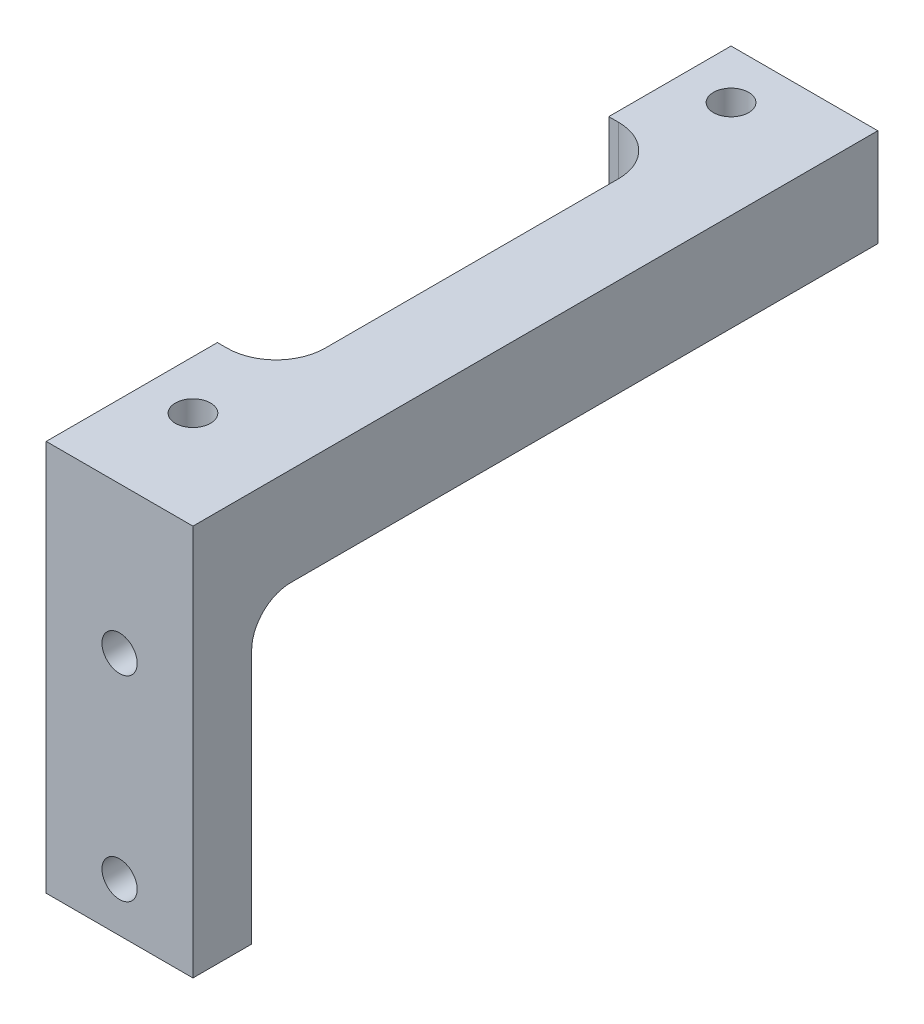
from build123d import *

# Parameters (mm, degrees)
SKETCH2_W           = 47.625
SKETCH2_H           = 25.4
BOSS_EXTRUDE1_DEPTH = 44.45
SKETCH3_W           = 28.575
SKETCH3_H           = 44.45
CUT_EXTRUDE1_DEPTH  = 26.4
SKETCH4_W           = 40.64
SKETCH4_H           = 19.05
CUT_EXTRUDE2_DEPTH  = 48.625
FILLET1_R           = 2.54
FILLET2_R           = 2.54
SKETCH5_R           = 1.143
CUT_EXTRUDE3_DEPTH  = 45.45
SKETCH6_R           = 1.143
CUT_EXTRUDE4_DEPTH  = 45.45
SKETCH7_R           = 1.143
CUT_EXTRUDE5_DEPTH  = 10.16
SKETCH8_W           = 36.195
SKETCH8_H           = 25.4
CUT_EXTRUDE6_DEPTH  = 26.4
FILLET3_R           = 3.175
FILLET4_R           = 3.175
SKETCH9_W           = 63.744217065
SKETCH9_H           = 41.287723533
CUT_EXTRUDE7_DEPTH  = 38.1


with BuildPart() as part:
    # Sketch2 → Boss-Extrude1 (new body)
    with BuildSketch(Plane.XY):
        Rectangle(SKETCH2_W, SKETCH2_H)
    extrude(amount=BOSS_EXTRUDE1_DEPTH)

    # Sketch3 → Cut-Extrude1 (cut, through all)
    with BuildSketch(Plane(origin=(0, 12.7, 0), x_dir=(1, 0, 0), z_dir=(0, 1, 0))):
        with Locations((0, -22.225)):
            Rectangle(SKETCH3_W, SKETCH3_H)
    extrude(amount=-CUT_EXTRUDE1_DEPTH, mode=Mode.SUBTRACT)

    # Sketch4 → Cut-Extrude2 (cut, through all)
    with BuildSketch(Plane.ZY.offset(23.8125)):
        with Locations((20.32, -3.175)):
            Rectangle(SKETCH4_W, SKETCH4_H)
    extrude(amount=-CUT_EXTRUDE2_DEPTH, mode=Mode.SUBTRACT)

    # Fillet1
    fillet1_edges = [part.edges().sort_by_distance(p)[0] for p in [
        (19.05, 6.35, 40.64),
    ]]
    fillet(fillet1_edges, radius=FILLET1_R)

    # Fillet2
    fillet2_edges = [part.edges().sort_by_distance(p)[0] for p in [
        (-19.05, 6.35, 40.64),
    ]]
    fillet(fillet2_edges, radius=FILLET2_R)

    # Sketch5 → Cut-Extrude3 (cut, through all)
    with BuildSketch(Plane.XY.offset(44.45)):
        with Locations((-19.05, -9.525)):
            Circle(SKETCH5_R)
        with Locations((-19.05, 3.175)):
            Circle(SKETCH5_R)
    extrude(amount=-CUT_EXTRUDE3_DEPTH, mode=Mode.SUBTRACT)

    # Sketch6 → Cut-Extrude4 (cut, through all)
    with BuildSketch(Plane.XY.offset(44.45)):
        with Locations((19.05, -9.525)):
            Circle(SKETCH6_R)
        with Locations((19.05, 3.175)):
            Circle(SKETCH6_R)
    extrude(amount=-CUT_EXTRUDE4_DEPTH, mode=Mode.SUBTRACT)

    # Sketch7 → Cut-Extrude5 (cut)
    with BuildSketch(Plane(origin=(0, 12.7, 0), x_dir=(1, 0, 0), z_dir=(0, 1, 0))):
        with Locations((-17.4625, -38.1)):
            Circle(SKETCH7_R)
        with Locations((17.4625, -38.1)):
            Circle(SKETCH7_R)
        with Locations((-17.4625, -3.175)):
            Circle(SKETCH7_R)
        with Locations((17.4625, -3.175)):
            Circle(SKETCH7_R)
    extrude(amount=-CUT_EXTRUDE5_DEPTH, mode=Mode.SUBTRACT)

    # Sketch8 → Cut-Extrude6 (cut, through all)
    with BuildSketch(Plane(origin=(0, 12.7, 0), x_dir=(1, 0, 0), z_dir=(0, 1, 0))):
        with Locations((0, -20.6375)):
            Rectangle(SKETCH8_W, SKETCH8_H)
    extrude(amount=-CUT_EXTRUDE6_DEPTH, mode=Mode.SUBTRACT)

    # Fillet3
    fillet3_edges = [part.edges().sort_by_distance(p)[0] for p in [
        (-18.0975, 9.525, 33.3375),
        (-18.0975, 9.525, 7.9375),
    ]]
    fillet(fillet3_edges, radius=FILLET3_R)

    # Fillet4
    fillet4_edges = [part.edges().sort_by_distance(p)[0] for p in [
        (18.0975, 9.525, 7.9375),
        (18.0975, 9.525, 33.3375),
    ]]
    fillet(fillet4_edges, radius=FILLET4_R)

    # Sketch9 → Cut-Extrude7 (cut)
    with BuildSketch(Plane(origin=(0, 0, 0), x_dir=(0, 0, -1), z_dir=(1, 0, 0))):
        with Locations((-15.024823823, -3.021052942)):
            Rectangle(SKETCH9_W, SKETCH9_H)
    extrude(amount=-CUT_EXTRUDE7_DEPTH, mode=Mode.SUBTRACT)


solid = part.part
